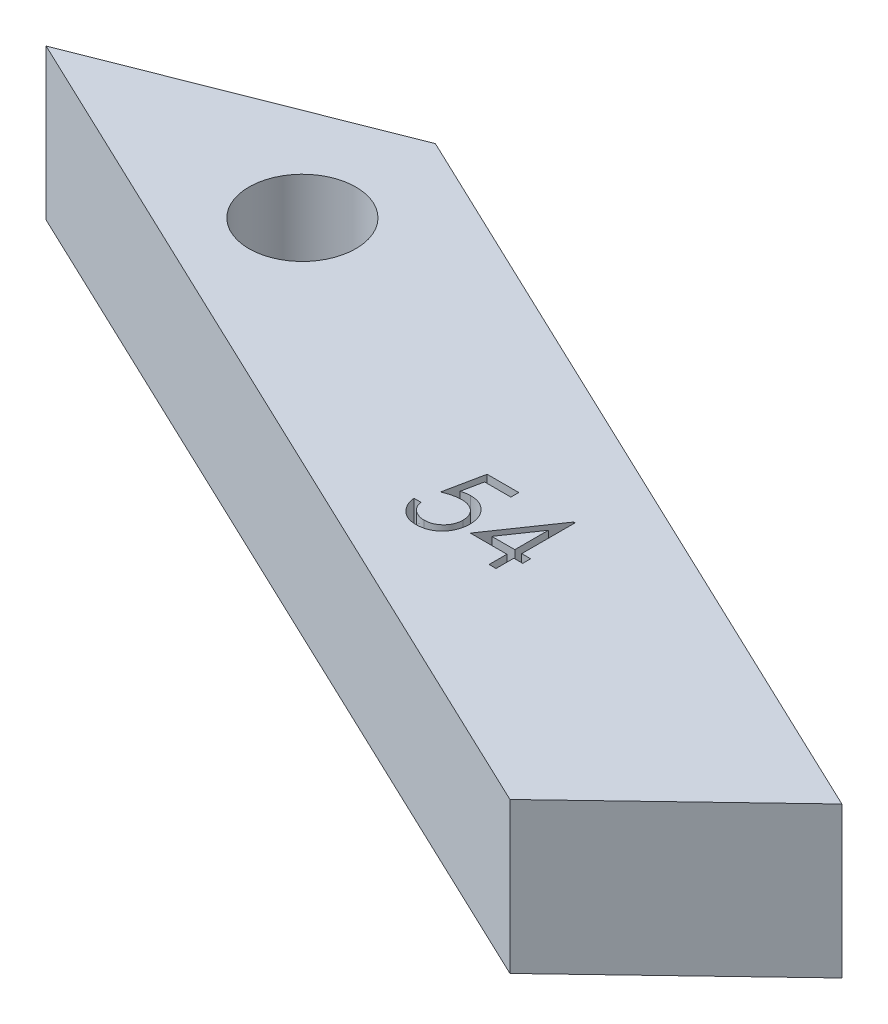
from build123d import *

# Parameters (mm, degrees)
SKETCH1_R           = 2.2
BOSS_EXTRUDE1_DEPTH = 6.2
CUT_EXTRUDE1_DEPTH  = 1


with BuildPart() as part:
    # Sketch1 → Boss-Extrude1 (new body)
    with BuildSketch(Plane(origin=(0, 0, 0), x_dir=(-1, 0, 0), z_dir=(0, 1, 0))):
        Polygon((-127.443880814, 98.339887686), (-134.435779681, 91.672540756), (-102.538529649, 76.502840404), (-91.051660388, 81.032468444), (-102.547087364, 86.499465833), align=None)
        with Locations((-102.448365494, 81.883499702)):
            Circle(SKETCH1_R, mode=Mode.SUBTRACT)
    extrude(amount=BOSS_EXTRUDE1_DEPTH)

    # Sketch2 → Cut-Extrude1 (cut)
    with BuildSketch(Plane(origin=(0, 6.2, 0), x_dir=(1, 0, 0), z_dir=(0, 1, 0))):
        with BuildLine():
            Line((116.688123147, -87.22045081), (116.688123147, -87.546091836))
            Line((116.688123147, -87.546091836), (115.608165214, -87.546091836))
            Line((115.608165214, -87.546091836), (115.437076472, -88.381182982))
            add(Edge.make_bspline(
                [(115.437076472, -88.381182982), (115.470691444, -88.371902664), (115.535815135, -88.353923515), (115.631935866, -88.333961138), (115.723187365, -88.321927485), (115.782401451, -88.320284368), (115.811054838, -88.319489272)],
                knots=[0, 0, 0, 0, 0.000104595, 0.000202637, 0.000294305, 0.000380252, 0.000380252, 0.000380252, 0.000380252], degree=3))
            add(Edge.make_bspline(
                [(115.811054838, -88.319489272), (115.846509373, -88.320256656), (115.916221848, -88.321765526), (116.018220035, -88.336254275), (116.115586303, -88.359059769), (116.208117024, -88.3909191), (116.295983381, -88.431658643), (116.378376955, -88.482549303), (116.45653449, -88.541997397), (116.529053843, -88.610346086), (116.594843751, -88.685567839), (116.652688613, -88.766446764), (116.70182182, -88.852196858), (116.741337648, -88.94363741), (116.772892008, -89.039757499), (116.793894175, -89.141568485), (116.807879332, -89.248110708), (116.809441783, -89.320958425), (116.810238532, -89.358106059)],
                knots=[0, 0, 0, 0, 0.000106308, 0.000209029, 0.000308378, 0.000405929, 0.000502102, 0.000598312, 0.00069588, 0.000796219, 0.000896736, 0.000995218, 0.001094066, 0.001192613, 0.001293582, 0.001396995, 0.001504047, 0.001615439, 0.001615439, 0.001615439, 0.001615439], degree=3))
            add(Edge.make_bspline(
                [(116.810238532, -89.358106059), (116.809635213, -89.383979787), (116.80843673, -89.435377583), (116.802342011, -89.511708394), (116.790607469, -89.586423249), (116.774852462, -89.659532062), (116.754403269, -89.730896421), (116.729648198, -89.800720593), (116.69935323, -89.868569986), (116.66612334, -89.935086594), (116.628706892, -89.998766669), (116.587179246, -90.058319678), (116.543304836, -90.11463899), (116.496095865, -90.167120591), (116.445113534, -90.215419615), (116.390975278, -90.259822698), (116.334113097, -90.301080762), (116.27364727, -90.337519054), (116.210925161, -90.371049735), (116.145040992, -90.398557516), (116.0774945, -90.423150638), (116.007313506, -90.442753566), (115.934656976, -90.458113812), (115.859405144, -90.4685465), (115.781952679, -90.476145125), (115.729451774, -90.476620792), (115.702931841, -90.476861067)],
                knots=[0, 0, 0, 0, 7.7636e-05, 0.000154223, 0.000229512, 0.000304362, 0.000378447, 0.000452077, 0.000526407, 0.000601214, 0.00067506, 0.000747747, 0.00081887, 0.000889121, 0.000959302, 0.001029336, 0.001099058, 0.00116985, 0.001240974, 0.00131221, 0.00138383, 0.001456517, 0.001530612, 0.001606437, 0.001684346, 0.001763871, 0.001763871, 0.001763871, 0.001763871], degree=3))
            add(Edge.make_bspline(
                [(115.702931841, -90.476861067), (115.671295977, -90.476234378), (115.609056152, -90.475001442), (115.517869638, -90.462103245), (115.430135674, -90.443630263), (115.346560511, -90.41583879), (115.26639515, -90.38101603), (115.190718827, -90.337004931), (115.117597873, -90.28713103), (115.050004812, -90.228275281), (114.987270337, -90.163944627), (114.93111229, -90.094133052), (114.88109826, -90.019992773), (114.83802916, -89.941163733), (114.80129167, -89.857853066), (114.77243093, -89.769748629), (114.749136994, -89.677310768), (114.73928232, -89.613671513), (114.734276993, -89.581348246)],
                knots=[0, 0, 0, 0, 9.4843e-05, 0.000186593, 0.000275792, 0.000363484, 0.000450342, 0.000537514, 0.000625728, 0.000715478, 0.000805885, 0.000894984, 0.00098389, 0.001073836, 0.001164117, 0.001256635, 0.001351658, 0.001449737, 0.001449737, 0.001449737, 0.001449737], degree=3))
            Line((114.734276993, -89.581348246), (115.019212891, -89.581348246))
            add(Edge.make_bspline(
                [(115.019212891, -89.581348246), (115.026223796, -89.611625457), (115.039699146, -89.669819936), (115.069277218, -89.751581939), (115.105441262, -89.824442949), (115.148443778, -89.889366785), (115.199742735, -89.945980661), (115.258280145, -89.996433282), (115.323909866, -90.041949292), (115.396838009, -90.079888516), (115.473775589, -90.112245171), (115.554300129, -90.133791352), (115.636219072, -90.148941447), (115.691625879, -90.150457973), (115.719468299, -90.151220041)],
                knots=[0, 0, 0, 0, 9.3172e-05, 0.000179081, 0.000260145, 0.000336703, 0.000411917, 0.000488562, 0.000568128, 0.000650923, 0.00073478, 0.000817953, 0.000900557, 0.000983994, 0.000983994, 0.000983994, 0.000983994], degree=3))
            add(Edge.make_bspline(
                [(115.719468299, -90.151220041), (115.746644888, -90.150475478), (115.800155814, -90.149009428), (115.878906143, -90.137725467), (115.954936393, -90.120346813), (116.027496353, -90.094339159), (116.097855749, -90.062730021), (116.164234813, -90.02216706), (116.228553851, -89.975485472), (116.288813658, -89.922003386), (116.34400373, -89.863066591), (116.392768211, -89.80004067), (116.433387268, -89.732806102), (116.467617496, -89.662526885), (116.493610131, -89.588432765), (116.512153021, -89.510870985), (116.52304151, -89.429649967), (116.524539366, -89.374251379), (116.525302634, -89.346021724)],
                knots=[0, 0, 0, 0, 8.15e-05, 0.000160473, 0.000238226, 0.000315066, 0.000391338, 0.000469218, 0.000547964, 0.000629516, 0.000710512, 0.000789892, 0.000868102, 0.000945761, 0.001024012, 0.00110315, 0.001184644, 0.001269321, 0.001269321, 0.001269321, 0.001269321], degree=3))
            add(Edge.make_bspline(
                [(116.525302634, -89.346021724), (116.524705299, -89.320553006), (116.523536101, -89.270701615), (116.513983369, -89.19776805), (116.497367259, -89.128758933), (116.474304168, -89.06334102), (116.445022043, -89.001452612), (116.409238602, -88.943029836), (116.366282306, -88.888842716), (116.317213235, -88.838865899), (116.263457727, -88.792742334), (116.204090903, -88.753423056), (116.140355112, -88.720345073), (116.073018261, -88.691799103), (116.000478675, -88.671296999), (115.924172873, -88.655904703), (115.843276859, -88.647000766), (115.787967735, -88.645765339), (115.75953741, -88.645130297)],
                knots=[0, 0, 0, 0, 7.6388e-05, 0.000149519, 0.000220172, 0.000288967, 0.000357247, 0.000425206, 0.000494043, 0.000564207, 0.000635056, 0.000706145, 0.000777268, 0.000850264, 0.000925136, 0.001002969, 0.001083601, 0.001168886, 0.001168886, 0.001168886, 0.001168886], degree=3))
            add(Edge.make_bspline(
                [(115.75953741, -88.645130297), (115.734927596, -88.645656977), (115.684114573, -88.646744435), (115.606170295, -88.654751329), (115.524262803, -88.667668403), (115.438706082, -88.685435928), (115.349243193, -88.708686976), (115.256062929, -88.736549416), (115.158969373, -88.769861515), (115.093548295, -88.795018594), (115.059918019, -88.80795081)],
                knots=[0, 0, 0, 0, 7.3822e-05, 0.000152423, 0.000234822, 0.000322511, 0.00041445, 0.000512043, 0.000614219, 0.000722306, 0.000722306, 0.000722306, 0.000722306], degree=3))
            Line((115.059918019, -88.80795081), (115.385559044, -87.22045081))
            Line((115.385559044, -87.22045081), (116.688123147, -87.22045081))
        make_face()
        Polygon((118.869027594, -87.139040554), (118.926905198, -87.139040554), (118.926905198, -89.337117477), (119.293251352, -89.337117477), (119.293251352, -89.662758503), (118.926905198, -89.662758503), (118.926905198, -90.39545081), (118.641969301, -90.39545081), (118.641969301, -89.662758503), (117.135879557, -89.662758503), align=None)
        Polygon((118.641969301, -89.337117477), (118.641969301, -87.958231259), (117.69557507, -89.337117477), align=None, mode=Mode.SUBTRACT)
    extrude(amount=-CUT_EXTRUDE1_DEPTH, mode=Mode.SUBTRACT)


solid = part.part
